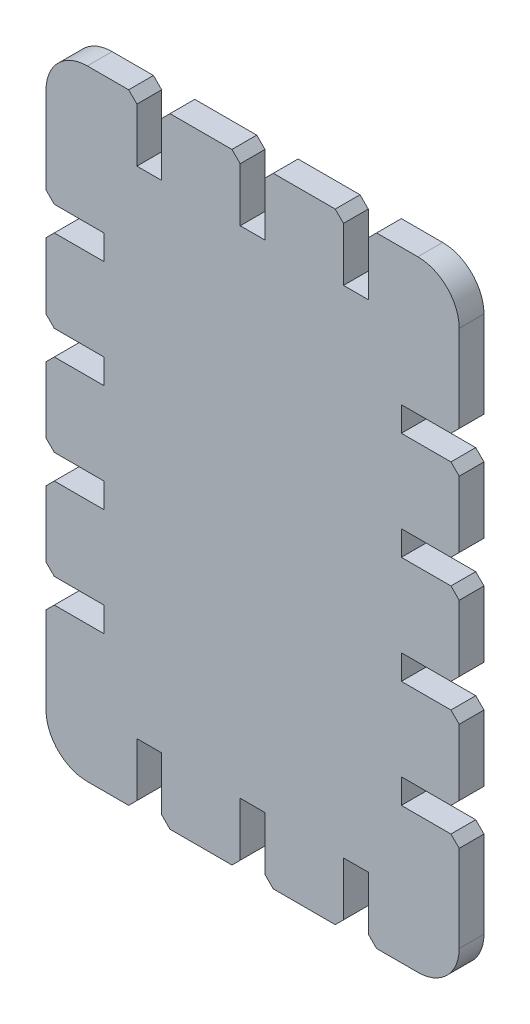
from build123d import *

# Parameters (mm, degrees)
BOSS_EXTRUDE1_DEPTH = 3


with BuildPart() as part:
    # Sketch1 → Boss-Extrude1 (new body)
    with BuildSketch(Plane.XY):
        with BuildLine():
            Line((-15.5, 27.693204924), (-8, 27.693204924))
            Line((-8, 27.693204924), (-7, 26.693204924))
            Line((-7, 26.693204924), (-7, 20.193204924))
            Line((-7, 20.193204924), (-4, 20.193204924))
            Line((-4, 20.193204924), (-4, 26.693204924))
            Line((-4, 26.693204924), (-3, 27.693204924))
            Line((-3, 27.693204924), (4.5, 27.693204924))
            Line((4.5, 27.693204924), (5.5, 26.693204924))
            Line((5.5, 26.693204924), (5.5, 20.193204924))
            Line((5.5, 20.193204924), (8.5, 20.193204924))
            Line((8.5, 20.193204924), (8.5, 26.693204924))
            Line((8.5, 26.693204924), (9.5, 27.693204924))
            Line((9.5, 27.693204924), (14.5, 27.693204924))
            ThreePointArc((14.5, 27.693204924), (18.035533906, 26.22873883), (19.5, 22.693204924))
            Line((19.5, 22.693204924), (19.5, 12.193204924))
            Line((19.5, 12.193204924), (18.5, 11.193204924))
            Line((18.5, 11.193204924), (12.5, 11.193204924))
            Line((12.5, 11.193204924), (12.5, 8.193204924))
            Line((12.5, 8.193204924), (18.5, 8.193204924))
            Line((18.5, 8.193204924), (19.5, 7.193204924))
            Line((19.5, 7.193204924), (19.5, -0.806795076))
            Line((19.5, -0.806795076), (18.5, -1.806795076))
            Line((18.5, -1.806795076), (12.5, -1.806795076))
            Line((12.5, -1.806795076), (12.5, -4.806795076))
            Line((12.5, -4.806795076), (18.5, -4.806795076))
            Line((18.5, -4.806795076), (19.5, -5.806795076))
            Line((19.5, -5.806795076), (19.5, -13.806795076))
            Line((19.5, -13.806795076), (18.5, -14.806795076))
            Line((18.5, -14.806795076), (12.5, -14.806795076))
            Line((12.5, -14.806795076), (12.5, -17.806795076))
            Line((12.5, -17.806795076), (18.5, -17.806795076))
            Line((18.5, -17.806795076), (19.5, -18.806795076))
            Line((19.5, -18.806795076), (19.5, -26.806795076))
            Line((19.5, -26.806795076), (18.5, -27.806795076))
            Line((18.5, -27.806795076), (12.5, -27.806795076))
            Line((12.5, -27.806795076), (12.5, -30.806795076))
            Line((12.5, -30.806795076), (18.5, -30.806795076))
            Line((18.5, -30.806795076), (19.5, -31.806795076))
            Line((19.5, -31.806795076), (19.5, -42.306795076))
            ThreePointArc((19.5, -42.306795076), (18.035533906, -45.842328982), (14.5, -47.306795076))
            Line((14.5, -47.306795076), (9.5, -47.306795076))
            Line((9.5, -47.306795076), (8.5, -46.306795076))
            Line((8.5, -46.306795076), (8.5, -39.806795076))
            Line((8.5, -39.806795076), (5.5, -39.806795076))
            Line((5.5, -39.806795076), (5.5, -46.306795076))
            Line((5.5, -46.306795076), (4.5, -47.306795076))
            Line((4.5, -47.306795076), (-3, -47.306795076))
            Line((-3, -47.306795076), (-4, -46.306795076))
            Line((-4, -46.306795076), (-4, -39.806795076))
            Line((-4, -39.806795076), (-7, -39.806795076))
            Line((-7, -39.806795076), (-7, -46.306795076))
            Line((-7, -46.306795076), (-8, -47.306795076))
            Line((-8, -47.306795076), (-15.5, -47.306795076))
            Line((-15.5, -47.306795076), (-16.5, -46.306795076))
            Line((-16.5, -46.306795076), (-16.5, -39.806795076))
            Line((-16.5, -39.806795076), (-19.5, -39.806795076))
            Line((-19.5, -39.806795076), (-19.5, -46.306795076))
            Line((-19.5, -46.306795076), (-20.5, -47.306795076))
            Line((-20.5, -47.306795076), (-25.5, -47.306795076))
            ThreePointArc((-25.5, -47.306795076), (-29.035533906, -45.842328982), (-30.5, -42.306795076))
            Line((-30.5, -42.306795076), (-30.5, -31.806795076))
            Line((-30.5, -31.806795076), (-29.5, -30.806795076))
            Line((-29.5, -30.806795076), (-23.5, -30.806795076))
            Line((-23.5, -30.806795076), (-23.5, -27.806795076))
            Line((-23.5, -27.806795076), (-29.5, -27.806795076))
            Line((-29.5, -27.806795076), (-30.5, -26.806795076))
            Line((-30.5, -26.806795076), (-30.5, -18.806795076))
            Line((-30.5, -18.806795076), (-29.5, -17.806795076))
            Line((-29.5, -17.806795076), (-23.5, -17.806795076))
            Line((-23.5, -17.806795076), (-23.5, -14.806795076))
            Line((-23.5, -14.806795076), (-29.5, -14.806795076))
            Line((-29.5, -14.806795076), (-30.5, -13.806795076))
            Line((-30.5, -13.806795076), (-30.5, -5.806795076))
            Line((-30.5, -5.806795076), (-29.5, -4.806795076))
            Line((-29.5, -4.806795076), (-23.5, -4.806795076))
            Line((-23.5, -4.806795076), (-23.5, -1.806795076))
            Line((-23.5, -1.806795076), (-29.5, -1.806795076))
            Line((-29.5, -1.806795076), (-30.5, -0.806795076))
            Line((-30.5, -0.806795076), (-30.5, 7.193204924))
            Line((-30.5, 7.193204924), (-29.5, 8.193204924))
            Line((-29.5, 8.193204924), (-23.5, 8.193204924))
            Line((-23.5, 8.193204924), (-23.5, 11.193204924))
            Line((-23.5, 11.193204924), (-29.5, 11.193204924))
            Line((-29.5, 11.193204924), (-30.5, 12.193204924))
            Line((-30.5, 12.193204924), (-30.5, 22.693204924))
            ThreePointArc((-30.5, 22.693204924), (-29.035533906, 26.22873883), (-25.5, 27.693204924))
            Line((-25.5, 27.693204924), (-20.5, 27.693204924))
            Line((-20.5, 27.693204924), (-19.5, 26.693204924))
            Line((-19.5, 26.693204924), (-19.5, 20.193204924))
            Line((-19.5, 20.193204924), (-16.5, 20.193204924))
            Line((-16.5, 20.193204924), (-16.5, 26.693204924))
            Line((-16.5, 26.693204924), (-15.5, 27.693204924))
        make_face()
    extrude(amount=BOSS_EXTRUDE1_DEPTH)


solid = part.part
